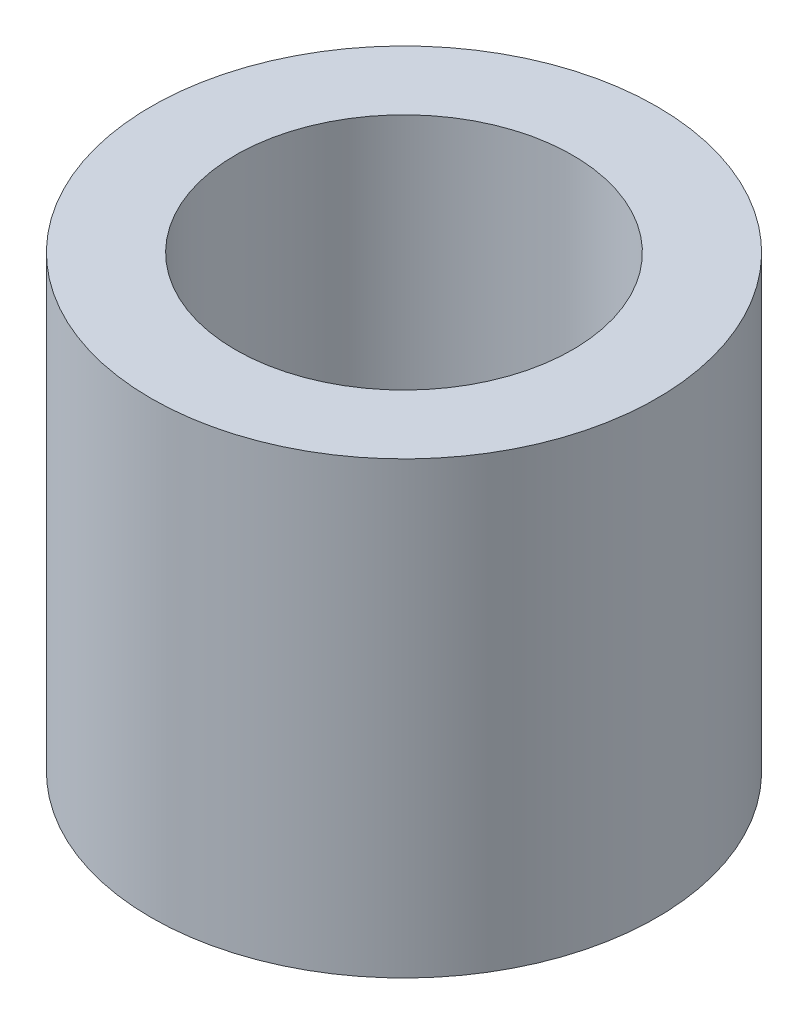
from build123d import *

# Parameters (mm, degrees)
SKETCH_1_R      = 2.25
SKETCH_1_R_2    = 1.5
EXTRUDE_1_DEPTH = 4


with BuildPart() as part:
    # 草图1 → 凸台-拉伸1 (new body)
    with BuildSketch(Plane(origin=(0, 0, 0), x_dir=(1, 0, 0), z_dir=(0, 1, 0))):
        Circle(SKETCH_1_R)
        Circle(SKETCH_1_R_2, mode=Mode.SUBTRACT)
    extrude(amount=EXTRUDE_1_DEPTH)


solid = part.part
